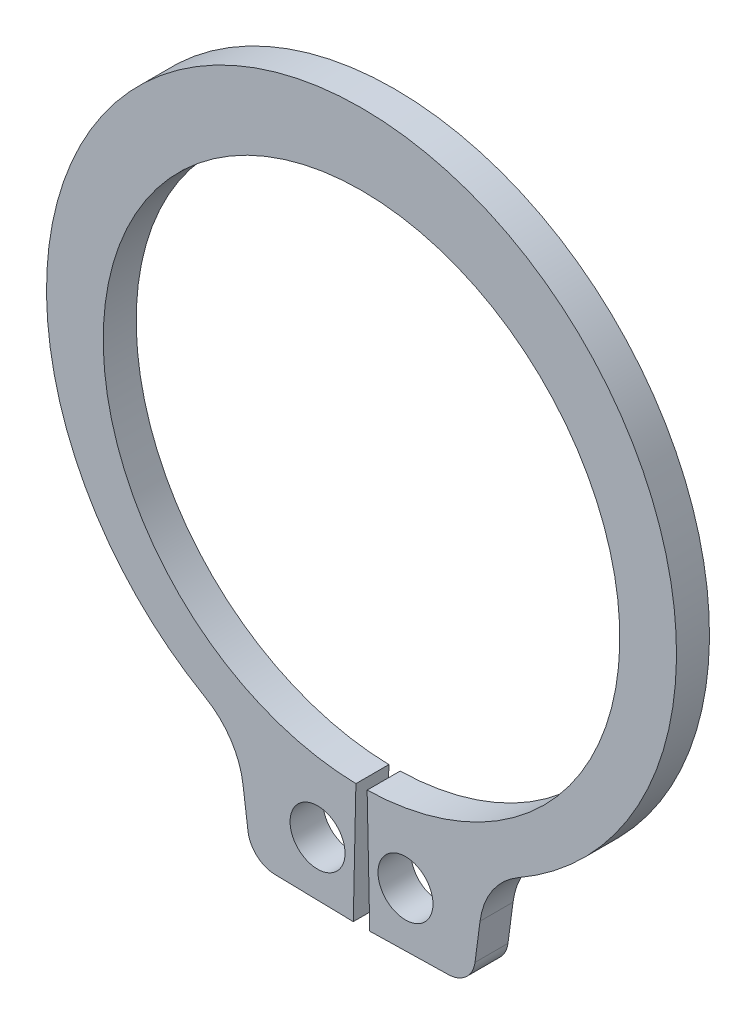
from build123d import *

# Parameters (mm, degrees)
BODYSKE_R  = 0.5
BODY_DEPTH = 0.6


with BuildPart() as part:
    # BodySke → Body (new body)
    with BuildSketch(Plane.XY):
        with BuildLine():
            Line((0.102173913, -4.698889283), (0.15, -6.898369373))
            Line((0.15, -6.898369373), (1.58019735, -6.867270777))
            ThreePointArc((1.58019735, -6.867270777), (1.903067541, -6.739703018), (2.065050215, -6.432652034))
            Line((2.065050215, -6.432652034), (2.156575283, -5.737450123))
            ThreePointArc((2.156575283, -5.737450123), (2.38183962, -5.140508531), (2.848648944, -4.705569062))
            ThreePointArc((2.848648944, -4.705569062), (0, 6), (-2.848648944, -4.705569062))
            ThreePointArc((-2.848648944, -4.705569062), (-2.38183962, -5.140508531), (-2.156575283, -5.737450123))
            Line((-2.156575283, -5.737450123), (-2.065050215, -6.432652034))
            ThreePointArc((-2.065050215, -6.432652034), (-1.903067541, -6.739703018), (-1.58019735, -6.867270777))
            Line((-1.58019735, -6.867270777), (-0.15, -6.898369373))
            Line((-0.15, -6.898369373), (-0.102173913, -4.698889283))
            ThreePointArc((-0.102173913, -4.698889283), (0, 4.7), (0.102173913, -4.698889283))
        make_face()
        with Locations((0.8, -5.895973202)):
            Circle(BODYSKE_R, mode=Mode.SUBTRACT)
        with Locations((-0.8, -5.895973202)):
            Circle(BODYSKE_R, mode=Mode.SUBTRACT)
    extrude(amount=-BODY_DEPTH)


solid = part.part
